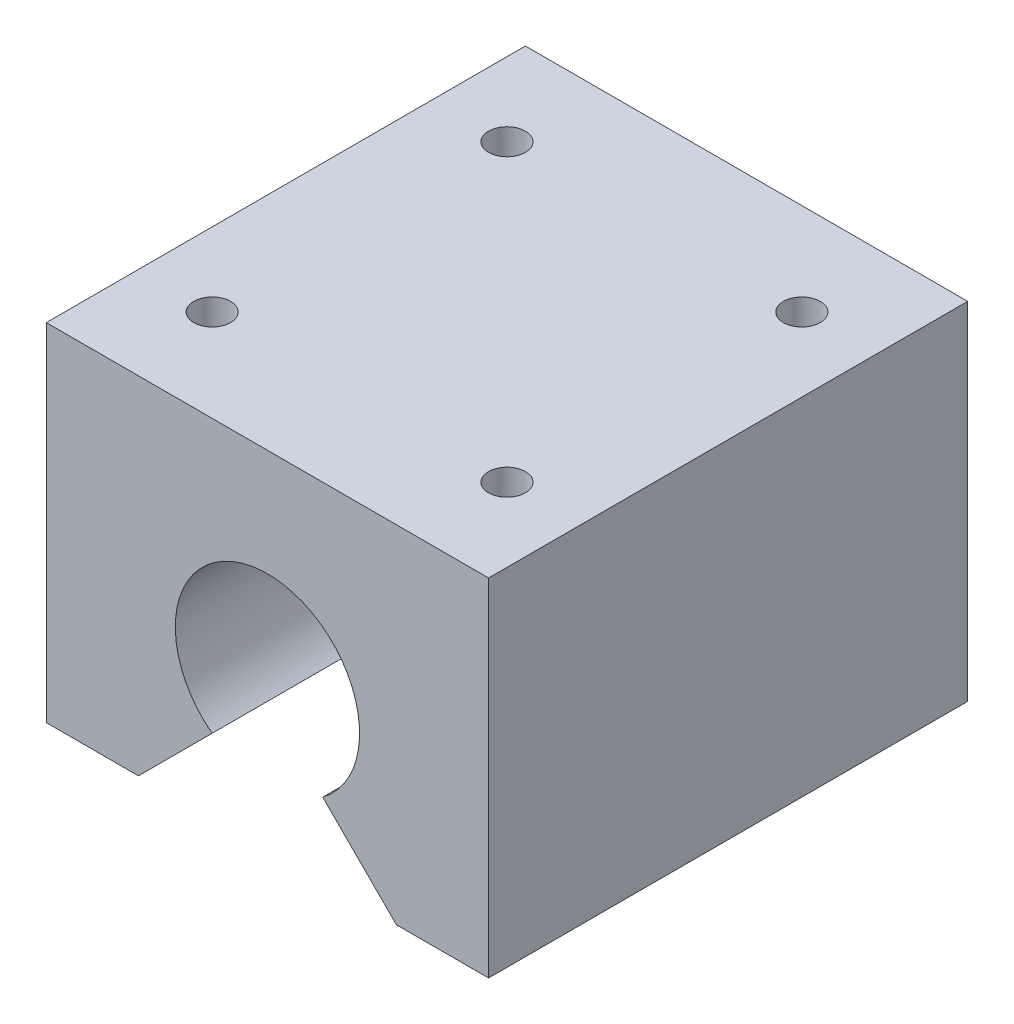
from build123d import *

# Parameters (mm, degrees)
EXTRUDE_1_DEPTH        = 32.5
HOLE_WIZARD_M6_1_D     = 5
HOLE_WIZARD_M6_1_DEPTH = 10
HOLE_WIZARD_M6_1_TIP   = 1.502151548


with BuildPart() as part:
    # 草图1 → 凸台-拉伸1 (new body, symmetric)
    with BuildSketch(Plane.XY):
        with BuildLine():
            Line((-17.5, 0), (-7.5, 10))
            ThreePointArc((-7.5, 10), (0, 32.5), (7.5, 10))
            Line((7.5, 10), (17.5, 0))
            Line((17.5, 0), (30, 0))
            Line((30, 0), (30, 47))
            Line((30, 47), (-30, 47))
            Line((-30, 47), (-30, 0))
            Line((-30, 0), (-17.5, 0))
        make_face()
    extrude(amount=EXTRUDE_1_DEPTH, both=True)

    # M6 螺纹孔1
    with Locations(Plane(origin=(-20, 47, -20), x_dir=(1, 0, 0), z_dir=(0, 1, 0))):
        with Locations((0, 0), (40, 0), (40, -40), (0, -40)):
            Hole(HOLE_WIZARD_M6_1_D / 2, depth=HOLE_WIZARD_M6_1_DEPTH)
            with Locations((0, 0, -(HOLE_WIZARD_M6_1_DEPTH + HOLE_WIZARD_M6_1_TIP / 2))):  # 118° drill point
                Cone(0, HOLE_WIZARD_M6_1_D / 2, HOLE_WIZARD_M6_1_TIP, mode=Mode.SUBTRACT)


solid = part.part
